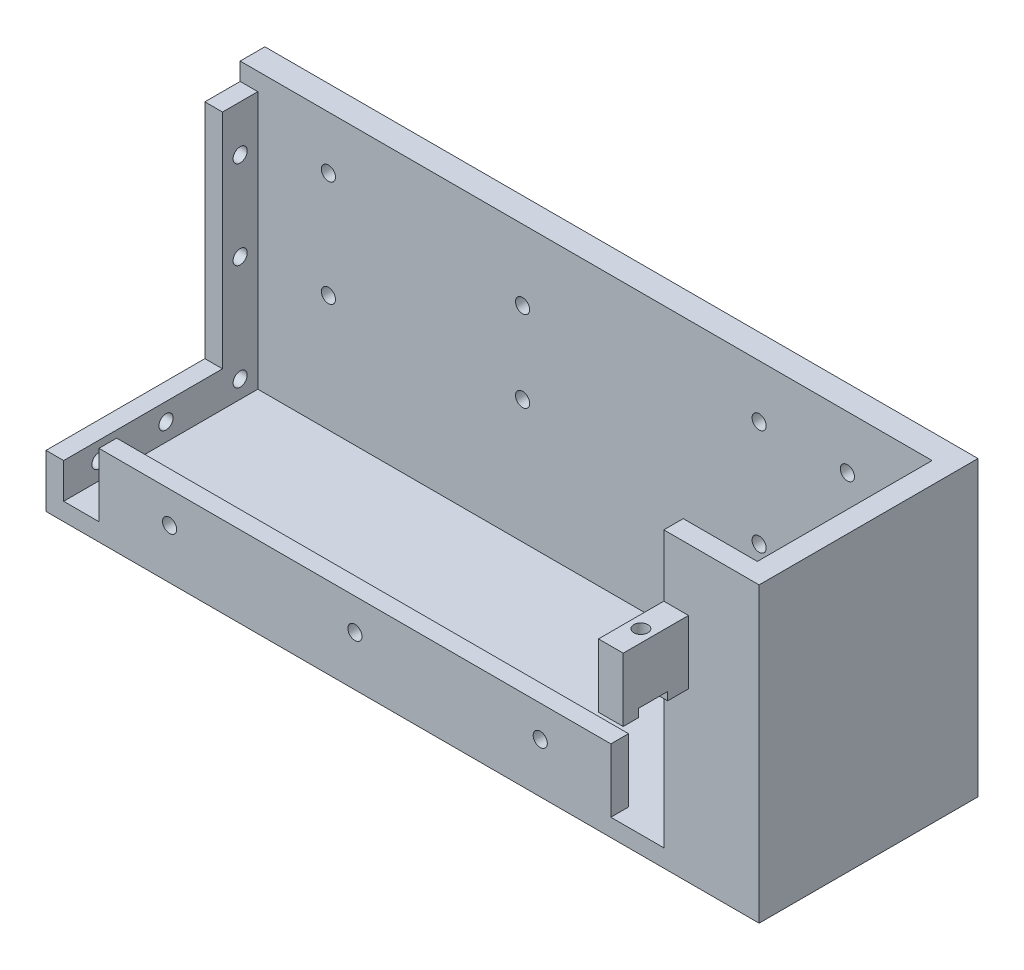
from build123d import *

# Parameters (mm, degrees)
SKETCH1_W           = 182
SKETCH1_H           = 62
BOSS_EXTRUDE1_DEPTH = 5
SKETCH2_W           = 145
SKETCH2_H           = 5
BOSS_EXTRUDE2_DEPTH = 18
SKETCH3_R           = 2
CUT_EXTRUDE1_DEPTH  = 18
SKETCH4_W           = 7
SKETCH4_H           = 62
BOSS_EXTRUDE3_DEPTH = 78
SKETCH5_W           = 175
SKETCH5_H           = 7
BOSS_EXTRUDE4_DEPTH = 78
SKETCH6_W           = 7
SKETCH6_H           = 18
BOSS_EXTRUDE5_DEPTH = 18.5
SKETCH7_R           = 2
CUT_EXTRUDE2_DEPTH  = 18
SKETCH8_W           = 7
SKETCH8_H           = 8.2
CUT_EXTRUDE3_DEPTH  = 2.3
SKETCH9_R           = 4.440846437
SKETCH9_R_2         = 4.5
CUT_EXTRUDE4_DEPTH  = 2.2
SKETCH12_W          = 5
SKETCH12_H          = 55
BOSS_EXTRUDE6_DEPTH = 10
SKETCH13_W          = 5
SKETCH13_H          = 10
BOSS_EXTRUDE7_DEPTH = 63
SKETCH15_R          = 2
CUT_EXTRUDE6_DEPTH  = 63
SKETCH16_W          = 62
SKETCH16_H          = 83
BOSS_EXTRUDE8_DEPTH = 20
SKETCH17_W          = 21
SKETCH17_H          = 49.5
CUT_EXTRUDE7_DEPTH  = 78
SKETCH18_R          = 2
CUT_EXTRUDE8_DEPTH  = 82
SKETCH19_R          = 2
CUT_EXTRUDE9_DEPTH  = 82
SKETCH21_R          = 2
CUT_EXTRUDE10_DEPTH = 10


with BuildPart() as part:
    # Sketch1 → Boss-Extrude1 (new body)
    with BuildSketch(Plane(origin=(0, 0, 0), x_dir=(1, 0, 0), z_dir=(0, 1, 0))):
        with Locations((46.151515152, -7.666666667)):
            Rectangle(SKETCH1_W, SKETCH1_H)
    extrude(amount=BOSS_EXTRUDE1_DEPTH)

    # Sketch2 → Boss-Extrude2 (add)
    with BuildSketch(Plane(origin=(0, 5, 0), x_dir=(1, 0, 0), z_dir=(0, 1, 0))):
        with Locations((49.651515152, -36.166666667)):
            Rectangle(SKETCH2_W, SKETCH2_H)
    extrude(amount=BOSS_EXTRUDE2_DEPTH)

    # Sketch3 → Cut-Extrude1 (cut)
    with BuildSketch(Plane(origin=(0, 0, 33.666666667), x_dir=(-1, 0, 0), z_dir=(0, 0, -1))):
        with Locations((-102.151515152, 14.1)):
            Circle(SKETCH3_R)
        with Locations((-49.651515152, 14.1)):
            Circle(SKETCH3_R)
        with Locations((2.848484848, 14.1)):
            Circle(SKETCH3_R)
    extrude(amount=-CUT_EXTRUDE1_DEPTH, mode=Mode.SUBTRACT)

    # Sketch4 → Boss-Extrude3 (add)
    with BuildSketch(Plane(origin=(0, 5, 0), x_dir=(1, 0, 0), z_dir=(0, 1, 0))):
        with Locations((-41.348484848, -7.666666667)):
            Rectangle(SKETCH4_W, SKETCH4_H)
    extrude(amount=BOSS_EXTRUDE3_DEPTH)

    # Sketch5 → Boss-Extrude4 (add)
    with BuildSketch(Plane(origin=(0, 5, 0), x_dir=(1, 0, 0), z_dir=(0, 1, 0))):
        with Locations((49.651515152, 19.833333333)):
            Rectangle(SKETCH5_W, SKETCH5_H)
    extrude(amount=BOSS_EXTRUDE4_DEPTH)

    # Sketch6 → Boss-Extrude5 (add)
    with BuildSketch(Plane.XY.offset(38.666666667)):
        with Locations((-41.348484848, 56.5)):
            Rectangle(SKETCH6_W, SKETCH6_H)
    extrude(amount=BOSS_EXTRUDE5_DEPTH)

    # Sketch7 → Cut-Extrude2 (cut)
    with BuildSketch(Plane(origin=(0, 65.5, 0), x_dir=(1, 0, 0), z_dir=(0, 1, 0))):
        with Locations((-41.348484848, -48.666666667)):
            Circle(SKETCH7_R)
    extrude(amount=-CUT_EXTRUDE2_DEPTH, mode=Mode.SUBTRACT)

    # Sketch8 → Cut-Extrude3 (cut)
    with BuildSketch(Plane.XZ.offset(-47.5)):
        with Locations((-41.348484848, 48.666666667)):
            Rectangle(SKETCH8_W, SKETCH8_H)
    extrude(amount=-CUT_EXTRUDE3_DEPTH, mode=Mode.SUBTRACT)

    # Sketch9 → Cut-Extrude4 (cut)
    with BuildSketch(Plane(origin=(0, 0, 33.666666667), x_dir=(-1, 0, 0), z_dir=(0, 0, -1))):
        with Locations((-102.151515152, 14.1)):
            Circle(SKETCH9_R)
        with Locations((-49.651515152, 14.1)):
            Circle(SKETCH9_R_2)
        with Locations((2.848484848, 14.1)):
            Circle(SKETCH9_R_2)
    extrude(amount=-CUT_EXTRUDE4_DEPTH, mode=Mode.SUBTRACT)

    # Sketch12 → Boss-Extrude6 (add)
    with BuildSketch(Plane(origin=(0, 5, 0), x_dir=(1, 0, 0), z_dir=(0, 1, 0))):
        with Locations((134.651515152, -11.166666667)):
            Rectangle(SKETCH12_W, SKETCH12_H)
    extrude(amount=BOSS_EXTRUDE6_DEPTH)

    # Sketch13 → Boss-Extrude7 (add)
    with BuildSketch(Plane(origin=(0, 15, 0), x_dir=(1, 0, 0), z_dir=(0, 1, 0))):
        with Locations((134.651515152, 11.333333333)):
            Rectangle(SKETCH13_W, SKETCH13_H)
    extrude(amount=BOSS_EXTRUDE7_DEPTH)

    # Sketch15 → Cut-Extrude6 (cut)
    with BuildSketch(Plane(origin=(137.151515152, 0, 0), x_dir=(0, 0, -1), z_dir=(1, 0, 0))):
        with Locations((11.333333333, 65)):
            Circle(SKETCH15_R)
        with Locations((11.333333333, 40)):
            Circle(SKETCH15_R)
        with Locations((11.333333333, 10)):
            Circle(SKETCH15_R)
        with Locations((-28.666666667, 10)):
            Circle(SKETCH15_R)
        with Locations((-9.666666667, 10)):
            Circle(SKETCH15_R)
    extrude(amount=-CUT_EXTRUDE6_DEPTH, mode=Mode.SUBTRACT)

    # Sketch16 → Boss-Extrude8 (add)
    with BuildSketch(Plane.ZY.offset(44.848484848)):
        with Locations((7.666666667, 41.5)):
            Rectangle(SKETCH16_W, SKETCH16_H)
    extrude(amount=BOSS_EXTRUDE8_DEPTH)

    # Sketch17 → Cut-Extrude7 (cut)
    with BuildSketch(Plane(origin=(0, 83, 0), x_dir=(1, 0, 0), z_dir=(0, 1, 0))):
        with Locations((-48.348484848, -8.416666667)):
            Rectangle(SKETCH17_W, SKETCH17_H)
    extrude(amount=-CUT_EXTRUDE7_DEPTH, mode=Mode.SUBTRACT)

    # Sketch18 → Cut-Extrude8 (cut)
    with BuildSketch(Plane.XY.offset(-16.333333333)):
        with Locations((-34.848484848, 68)):
            Circle(SKETCH18_R)
        with Locations((-9.848484848, 68)):
            Circle(SKETCH18_R)
        with Locations((-34.848484848, 38)):
            Circle(SKETCH18_R)
        with Locations((-9.848484848, 38)):
            Circle(SKETCH18_R)
    extrude(amount=-CUT_EXTRUDE8_DEPTH, mode=Mode.SUBTRACT)

    # Sketch19 → Cut-Extrude9 (cut)
    with BuildSketch(Plane.XY.offset(-16.333333333)):
        with Locations((57.151515152, 63)):
            Circle(SKETCH19_R)
        with Locations((57.151515152, 40)):
            Circle(SKETCH19_R)
    extrude(amount=-CUT_EXTRUDE9_DEPTH, mode=Mode.SUBTRACT)

    # Sketch21 → Cut-Extrude10 (cut)
    with BuildSketch(Plane(origin=(0, 0, -23.333333333), x_dir=(-1, 0, 0), z_dir=(0, 0, -1))):
        with Locations((-112.151515152, 38)):
            Circle(SKETCH21_R)
        with Locations((-112.151515152, 68)):
            Circle(SKETCH21_R)
    extrude(amount=-CUT_EXTRUDE10_DEPTH, mode=Mode.SUBTRACT)


with BuildPart() as body_2:
    # Mirror1: mirrored copy
    add(part.part.mirror(Plane.ZY.offset(64.848484848)))


solid = body_2.part
